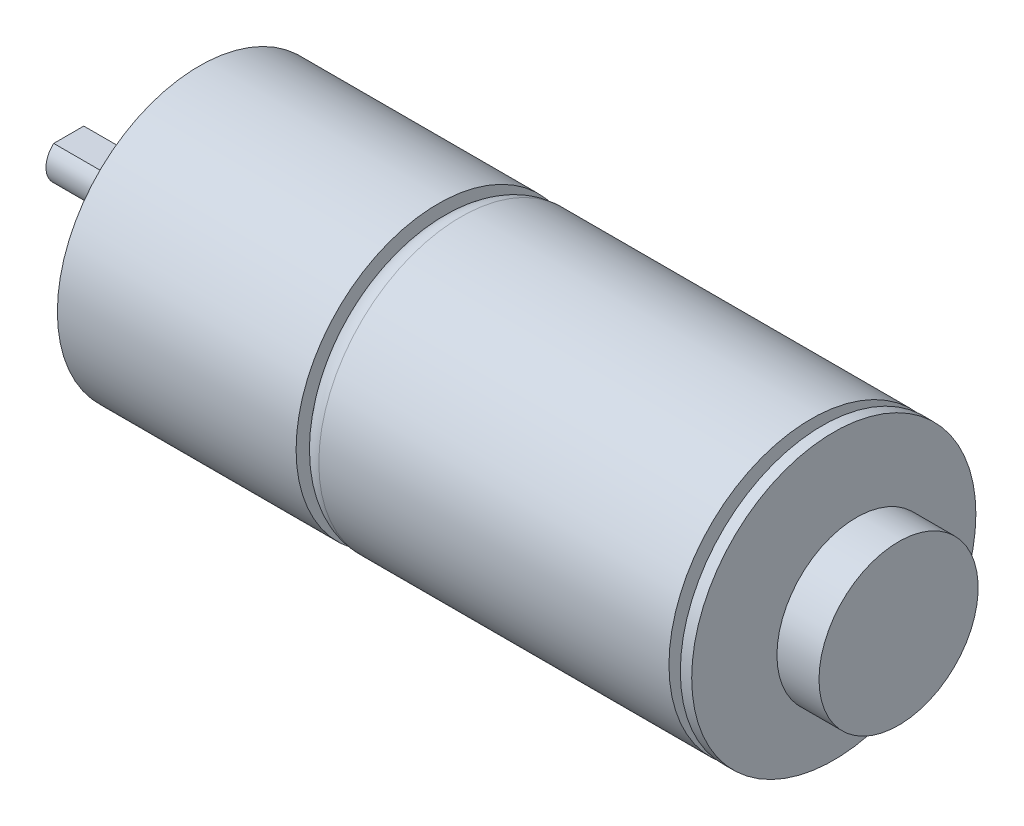
from build123d import *

# Parameters (mm, degrees)
TAP_DRILL_FOR_M3X0_5_TAP1_D     = 2.5
TAP_DRILL_FOR_M3X0_5_TAP1_DEPTH = 3
TAP_DRILL_FOR_M3X0_5_TAP1_TIP   = 0.751075774
SKETCH5_W                       = 8
SKETCH5_H                       = 0.5
CUT_EXTRUDE1_DEPTH              = 13.5
CUT_EXTRUDE1_DEPTH_BACK         = 13.5


with BuildPart() as part:
    # Sketch1 → Revolve1 (revolve)
    with BuildSketch(Plane.XY):
        with BuildLine():
            Line((0, 0), (0, 2))
            Line((0, 2), (9, 2))
            ThreePointArc((9, 2), (9.439339828, 3.060660172), (10.5, 3.5))
            Line((10.5, 3.5), (11.5, 3.5))
            Line((11.5, 3.5), (11.5, 12.5))
            Line((11.5, 12.5), (32.5, 12.5))
            Line((32.5, 12.5), (32.5, 10.5))
            ThreePointArc((32.5, 10.5), (33.085786438, 11.914213562), (34.5, 12.5))
            Line((34.5, 12.5), (65.3, 12.5))
            Line((65.3, 12.5), (65.3, 3.5))
            Line((65.3, 3.5), (66.3, 3.5))
            Line((66.3, 3.5), (66.3, 12.5))
            Line((66.3, 12.5), (67.3, 12.5))
            Line((67.3, 12.5), (67.3, 2.5))
            Line((67.3, 2.5), (69.3, 2.5))
            Line((69.3, 2.5), (69.3, 7))
            Line((69.3, 7), (73, 7))
            Line((73, 7), (73, 0))
            Line((73, 0), (0, 0))
        make_face()
    revolve(axis=Axis((0, 0, 0), (1, 0, 0)))

    # Tap Drill for M3x0.5 Tap1
    with Locations(Plane.ZY.offset(-11.5)):
        with Locations((-8.5, 0), (8.5, 0)):
            Hole(TAP_DRILL_FOR_M3X0_5_TAP1_D / 2, depth=TAP_DRILL_FOR_M3X0_5_TAP1_DEPTH)
            with Locations((0, 0, -(TAP_DRILL_FOR_M3X0_5_TAP1_DEPTH + TAP_DRILL_FOR_M3X0_5_TAP1_TIP / 2))):  # 118° drill point
                Cone(0, TAP_DRILL_FOR_M3X0_5_TAP1_D / 2, TAP_DRILL_FOR_M3X0_5_TAP1_TIP, mode=Mode.SUBTRACT)

    # Sketch5 → Cut-Extrude1 (cut, two sides)
    with BuildSketch(Plane.XY) as cut_extrude1_sk:
        with Locations((4, 1.75)):
            Rectangle(SKETCH5_W, SKETCH5_H)
    extrude(amount=CUT_EXTRUDE1_DEPTH, mode=Mode.SUBTRACT)
    extrude(cut_extrude1_sk.sketch, amount=-CUT_EXTRUDE1_DEPTH_BACK, mode=Mode.SUBTRACT)


solid = part.part
